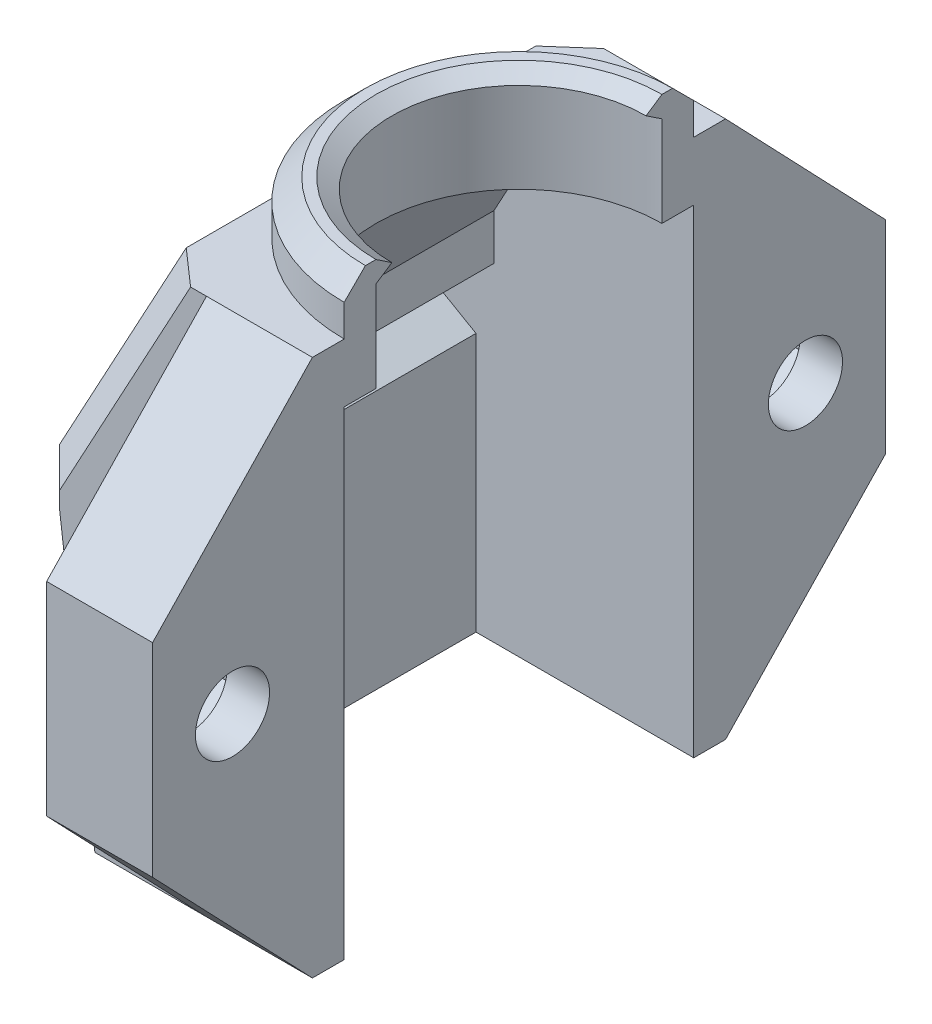
from build123d import *

# Parameters (mm, degrees)
BOSS_EXTRUDE1_DEPTH = 19.5
BOSS_EXTRUDE5_DEPTH = 1.5
BOSS_EXTRUDE6_DEPTH = 1.5
SKETCH8_R           = 6.75
CUT_EXTRUDE2_DEPTH  = 35.70752685
BOSS_EXTRUDE7_DEPTH = 2.5
SKETCH10_R          = 1.75
BOSS_EXTRUDE8_DEPTH = 5
CHAMFER1_SIZE       = 1.5
SKETCH11_R          = 1.75
CUT_EXTRUDE3_DEPTH  = 3
CHAMFER2_SIZE       = 1
REVOLVE1_ANGLE      = 180


with BuildPart() as part:
    # Sketch1 → Boss-Extrude1 (new body)
    with BuildSketch(Plane.XY):
        Polygon((-11.779, -12.684829289), (-10.279, -12.684829289), (-10.279, -0.473504424), (-11.944063509, 0.487820441), (-11.944063509, 1.64252098), (-9.912974596, 2.815170711), (-9.427494989, 2.815170711), (-9.427494989, 4.973204454), (-6.75, 9.910826582), (0, 9.910826582), (0, 12.684829289), (-7.456216647, 12.684829289), (-13.444063509, 1.64252098), (-13.444063509, 0.487820441), align=None)
    extrude(amount=BOSS_EXTRUDE1_DEPTH)

    # Sketch6 → Boss-Extrude5 (add)
    with BuildSketch(Plane.XY.offset(19.5)):
        Polygon((0, 12.684829289), (-7.456216647, 12.684829289), (-13.444063509, 1.64252098), (-13.444063509, 0.487820441), (-11.779, -12.684829289), (0, -12.684829289), align=None)
    extrude(amount=-BOSS_EXTRUDE5_DEPTH)

    # Sketch7 → Boss-Extrude6 (add)
    with BuildSketch(Plane(origin=(0, 0, 0), x_dir=(-1, 0, 0), z_dir=(0, 0, -1))):
        Polygon((0, 12.684829289), (0, -12.684829289), (11.779, -12.684829289), (13.444063509, 0.487820441), (13.444063509, 1.64252098), (7.456216647, 12.684829289), align=None)
    extrude(amount=-BOSS_EXTRUDE6_DEPTH)

    # Sketch8 → Cut-Extrude2 (cut, through all)
    with BuildSketch(Plane(origin=(0, 12.684829289, 0), x_dir=(1, 0, 0), z_dir=(0, 1, 0))):
        with Locations((0, -9.75)):
            Circle(SKETCH8_R)
    extrude(amount=-CUT_EXTRUDE2_DEPTH, mode=Mode.SUBTRACT)

    # Sketch9 → Boss-Extrude7 (add, symmetric)
    with BuildSketch(Plane(origin=(0, 12.684829289, 0), x_dir=(1, 0, 0), z_dir=(0, 1, 0))):
        with BuildLine():
            Line((0, -1.5), (0, -3))
            ThreePointArc((0, -3), (-6.75, -9.75), (0, -16.5))
            Line((0, -16.5), (0, -18))
            ThreePointArc((0, -18), (-8.25, -9.75), (0, -1.5))
        make_face()
    extrude(amount=BOSS_EXTRUDE7_DEPTH, both=True)

    # Sketch10 → Boss-Extrude8 (add)
    with BuildSketch(Plane(origin=(0, 0, 0), x_dir=(0, 0, -1), z_dir=(1, 0, 0))):
        Polygon((-19.5, 12.684829289), (-27.043783602, 4.79693847), (-27.043783602, -4.79693847), (-19.5, -12.684829289), align=None)
        Polygon((-20.396891801, -1.659882024), (-20.396891801, 1.659882024), (-23.271891801, 3.319764048), (-26.146891801, 1.659882024), (-26.146891801, -1.659882024), (-23.271891801, -3.319764048), align=None, mode=Mode.SUBTRACT)
        Polygon((-23.271891801, -3.319764048), (-20.396891801, -1.659882024), (-20.396891801, 1.659882024), (-23.271891801, 3.319764048), (-26.146891801, 1.659882024), (-26.146891801, -1.659882024), align=None)
        with Locations(Location((-23.271891801, 0, 0), (0, 0, 90))):
            Circle(SKETCH10_R, mode=Mode.SUBTRACT)
        Polygon((7.543783602, 4.79693847), (0, 12.684829289), (0, -12.684829289), (7.543783602, -4.79693847), align=None)
        Polygon((6.646891801, 1.659882024), (3.771891801, 3.319764048), (0.896891801, 1.659882024), (0.896891801, -1.659882024), (3.771891801, -3.319764048), (6.646891801, -1.659882024), align=None, mode=Mode.SUBTRACT)
        Polygon((6.646891801, 1.659882024), (6.646891801, -1.659882024), (3.771891801, -3.319764048), (0.896891801, -1.659882024), (0.896891801, 1.659882024), (3.771891801, 3.319764048), align=None)
        with Locations(Location((3.771891801, 0, 0), (0, 0, 90))):
            Circle(SKETCH10_R, mode=Mode.SUBTRACT)
    extrude(amount=-BOSS_EXTRUDE8_DEPTH)

    # Chamfer1
    chamfer1_edges = [part.edges().sort_by_distance(p)[0] for p in [
        (-12.611531755, -6.098504424, 19.5),
        (-13.444063509, 1.065170711, 19.5),
        (-10.450140078, 7.163675135, 19.5),
        (-12.611531755, -6.098504424, 0),
        (-13.444063509, 1.065170711, 0),
        (-10.450140078, 7.163675135, 0),
    ]]
    chamfer(chamfer1_edges, length=CHAMFER1_SIZE)

    # Sketch11 → Cut-Extrude3 (cut)
    with BuildSketch(Plane.ZY.offset(5)):
        Polygon((-6.646891801, 1.659882024), (-3.771891801, 3.319764048), (-0.896891801, 1.659882024), (-0.896891801, -1.659882024), (-3.771891801, -3.319764048), (-6.646891801, -1.659882024), align=None)
        with Locations(Location((-3.771891801, 0, 0), (0, 0, 90))):
            Circle(SKETCH11_R, mode=Mode.SUBTRACT)
        Polygon((20.396891801, 1.659882024), (23.271891801, 3.319764048), (26.146891801, 1.659882024), (26.146891801, -1.659882024), (23.271891801, -3.319764048), (20.396891801, -1.659882024), align=None)
        with Locations(Location((23.271891801, 0, 0), (0, 0, 90))):
            Circle(SKETCH11_R, mode=Mode.SUBTRACT)
    extrude(amount=-CUT_EXTRUDE3_DEPTH, mode=Mode.SUBTRACT)

    # Chamfer2
    chamfer2_edges = [part.edges().sort_by_distance(p)[0] for p in [
        (-8.25, 15.184829289, 9.75),
    ]]
    chamfer(chamfer2_edges, length=CHAMFER2_SIZE)

    # Sketch12 → Revolve1 (revolve)
    with BuildSketch(Plane(origin=(0, 0, 0), x_dir=(0, 0, -1), z_dir=(1, 0, 0))):
        Polygon((-16.5, 15.184829289), (-16.5, 14.184829289), (-15.75, 14.684829289), align=None)
    revolve(axis=Axis((0, 15.184829289, 9.75), (0, -1, 0)), revolution_arc=REVOLVE1_ANGLE)


solid = part.part
